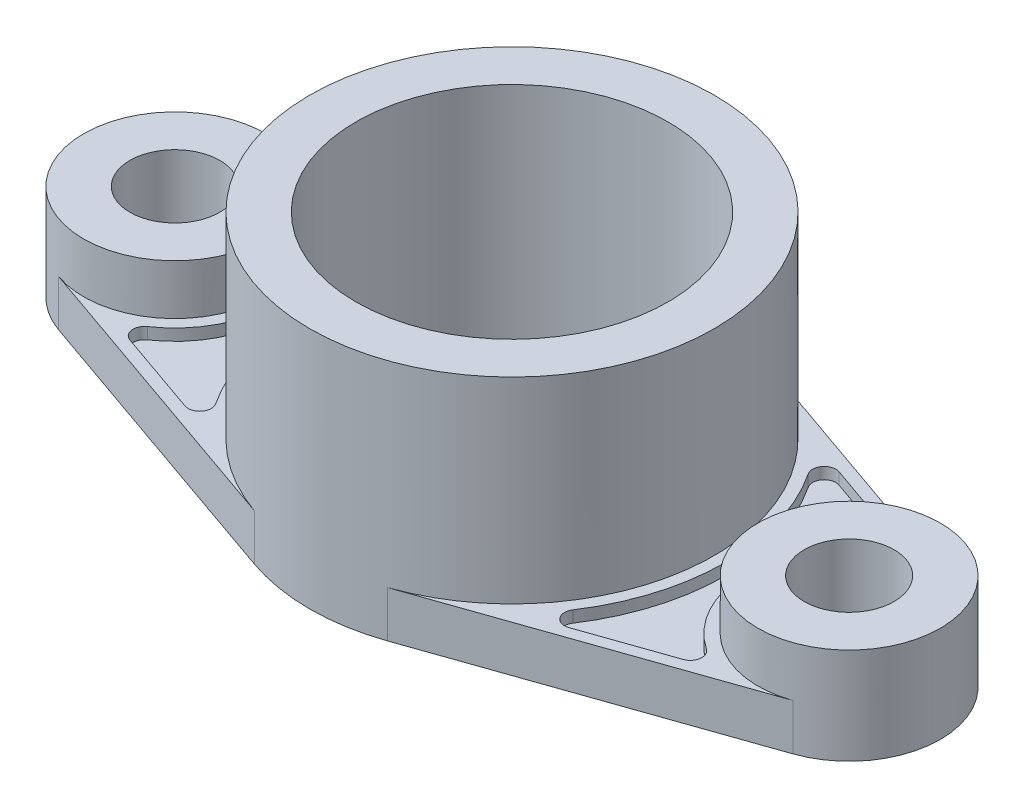
from build123d import *

# Parameters (mm, degrees)
BOSS_EXTRUDE1_DEPTH = 12
BOSS_EXTRUDE2_DEPTH = 9
BOSS_EXTRUDE3_DEPTH = 12
SKETCH1_5_R         = 40.5
BOSS_EXTRUDE4_DEPTH = 63
SKETCH1_6_R         = 23.665
SKETCH1_6_R_2       = 11.665
BOSS_EXTRUDE5_DEPTH = 25


with BuildPart() as part:
    # Sketch1 → Boss-Extrude1 (new body)
    with BuildSketch(Plane(origin=(0, 0, 0), x_dir=(1, 0, 0), z_dir=(0, 1, 0))):
        with BuildLine():
            Line((95.298631714, 22.343087709), (17.301, 49.56738241))
            ThreePointArc((17.301, 49.56738241), (42.805096075, 30.396936523), (52.5, 0))
            ThreePointArc((52.5, 0), (42.805096075, -30.396936523), (17.301, -49.56738241))
            Line((17.301, -49.56738241), (95.298631714, -22.343087709))
            ThreePointArc((95.298631714, -22.343087709), (63.835, 0), (95.298631714, 22.343087709))
        make_face()
        with BuildLine():
            Line((71.809327621, -27.364302024), (49.82603874, -35.037349549))
            ThreePointArc((49.82603874, -35.037349549), (46.470783868, -34.048587089), (46.332927596, -30.553392944))
            ThreePointArc((46.332927596, -30.553392944), (55.5, 0), (46.332927596, 30.553392944))
            ThreePointArc((46.332927596, 30.553392944), (46.470783868, 34.048587089), (49.82603874, 35.037349549))
            Line((49.82603874, 35.037349549), (71.809327621, 27.364302024))
            ThreePointArc((71.809327621, 27.364302024), (73.795133067, 24.922702734), (72.507464694, 22.050988869))
            ThreePointArc((72.507464694, 22.050988869), (60.835, 0), (72.507464694, -22.050988869))
            ThreePointArc((72.507464694, -22.050988869), (73.795133067, -24.922702734), (71.809327621, -27.364302024))
        make_face(mode=Mode.SUBTRACT)
    extrude(amount=BOSS_EXTRUDE1_DEPTH)

    # Sketch1_3 → Boss-Extrude2 (add)
    with BuildSketch(Plane(origin=(0, 0, 0), x_dir=(1, 0, 0), z_dir=(0, 1, 0))):
        with BuildLine():
            Line((-49.82603874, 35.037349549), (-71.809327621, 27.364302024))
            ThreePointArc((-71.809327621, 27.364302024), (-73.795133067, 24.922702734), (-72.507464694, 22.050988869))
            ThreePointArc((-72.507464694, 22.050988869), (-60.835, 0), (-72.507464694, -22.050988869))
            ThreePointArc((-72.507464694, -22.050988869), (-73.795133067, -24.922702734), (-71.809327621, -27.364302024))
            Line((-71.809327621, -27.364302024), (-49.82603874, -35.037349549))
            ThreePointArc((-49.82603874, -35.037349549), (-46.470783868, -34.048587089), (-46.332927596, -30.553392944))
            ThreePointArc((-46.332927596, -30.553392944), (-55.5, 0), (-46.332927596, 30.553392944))
            ThreePointArc((-46.332927596, 30.553392944), (-46.470783868, 34.048587089), (-49.82603874, 35.037349549))
        make_face()
        with BuildLine():
            ThreePointArc((46.332927596, -30.553392944), (46.470783868, -34.048587089), (49.82603874, -35.037349549))
            Line((49.82603874, -35.037349549), (71.809327621, -27.364302024))
            ThreePointArc((71.809327621, -27.364302024), (73.795133067, -24.922702734), (72.507464694, -22.050988869))
            ThreePointArc((72.507464694, -22.050988869), (60.835, 0), (72.507464694, 22.050988869))
            ThreePointArc((72.507464694, 22.050988869), (73.795133067, 24.922702734), (71.809327621, 27.364302024))
            Line((71.809327621, 27.364302024), (49.82603874, 35.037349549))
            ThreePointArc((49.82603874, 35.037349549), (46.470783868, 34.048587089), (46.332927596, 30.553392944))
            ThreePointArc((46.332927596, 30.553392944), (55.5, 0), (46.332927596, -30.553392944))
        make_face()
    extrude(amount=BOSS_EXTRUDE2_DEPTH)


with BuildPart() as boss_extrude2_piece_1:
    # of the separate pieces the step leaves, piece 1, a body of its own (boss_extrude2_pieces)
    add(part.part.solids().sort_by_distance((17.301, 0, 49.56738241))[0])



with BuildPart() as boss_extrude2_piece_2:
    # of the separate pieces the step leaves, piece 2, a body of its own (boss_extrude2_pieces)
    add(part.part.solids().sort_by_distance((-46.332927596, 0, -30.553392944))[0])

    # Sketch1_4 → Boss-Extrude3 (add)
    with BuildSketch(Plane(origin=(0, 0, 0), x_dir=(1, 0, 0), z_dir=(0, 1, 0))):
        with BuildLine():
            Line((-37.609789084, 42.478802323), (-95.298631714, 22.343087709))
            ThreePointArc((-95.298631714, 22.343087709), (-73.798218994, 19.29490664), (-63.835, 0))
            ThreePointArc((-63.835, 0), (-73.798218994, -19.29490664), (-95.298631714, -22.343087709))
            Line((-95.298631714, -22.343087709), (-17.301, -49.56738241))
            ThreePointArc((-17.301, -49.56738241), (-52.498391324, -0.410984604), (-18.074910259, 49.290441458))
            Line((-18.074910259, 49.290441458), (-37.609789084, 42.478802323))
        make_face()
        with BuildLine():
            ThreePointArc((-72.507464694, 22.050988869), (-73.795133067, 24.922702734), (-71.809327621, 27.364302024))
            Line((-71.809327621, 27.364302024), (-49.82603874, 35.037349549))
            ThreePointArc((-49.82603874, 35.037349549), (-46.470783868, 34.048587089), (-46.332927596, 30.553392944))
            ThreePointArc((-46.332927596, 30.553392944), (-55.5, 0), (-46.332927596, -30.553392944))
            ThreePointArc((-46.332927596, -30.553392944), (-46.470783868, -34.048587089), (-49.82603874, -35.037349549))
            Line((-49.82603874, -35.037349549), (-71.809327621, -27.364302024))
            ThreePointArc((-71.809327621, -27.364302024), (-73.795133067, -24.922702734), (-72.507464694, -22.050988869))
            ThreePointArc((-72.507464694, -22.050988869), (-60.835, 0), (-72.507464694, 22.050988869))
        make_face(mode=Mode.SUBTRACT)
    extrude(amount=BOSS_EXTRUDE3_DEPTH)


with BuildPart() as boss_extrude2_piece_1_1:
    add(boss_extrude2_piece_1.part)

    add(boss_extrude2_piece_2.part)  # Boss-Extrude4 merges Boss-Extrude2 piece 2
    # Sketch1_5 → Boss-Extrude4 (add)
    with BuildSketch(Plane(origin=(0, 0, 0), x_dir=(1, 0, 0), z_dir=(0, 1, 0))):
        with BuildLine():
            ThreePointArc((17.301, 49.56738241), (-0.410984604, 52.498391324), (-18.074910259, 49.290441458))
            ThreePointArc((-18.074910259, 49.290441458), (-52.498391324, -0.410984604), (-17.301, -49.56738241))
            ThreePointArc((-17.301, -49.56738241), (0, -52.5), (17.301, -49.56738241))
            ThreePointArc((17.301, -49.56738241), (42.805096075, -30.396936523), (52.5, 0))
            ThreePointArc((52.5, 0), (42.805096075, 30.396936523), (17.301, 49.56738241))
        make_face()
        Circle(SKETCH1_5_R, mode=Mode.SUBTRACT)
    extrude(amount=BOSS_EXTRUDE4_DEPTH)

    # Sketch1_6 → Boss-Extrude5 (add)
    # profile 1 of 2: a face of its own
    with BuildSketch(Plane(origin=(0, 0, 0), x_dir=(1, 0, 0), z_dir=(0, 1, 0))):
        with Locations((-87.5, 0)):
            Circle(SKETCH1_6_R)
        with Locations((-87.5, 0)):
            Circle(SKETCH1_6_R_2, mode=Mode.SUBTRACT)
    # profile 2 of 2: a face of its own
    with BuildSketch(Plane(origin=(0, 0, 0), x_dir=(1, 0, 0), z_dir=(0, 1, 0))):
        with Locations((87.5, 0)):
            Circle(SKETCH1_6_R)
        with Locations((87.5, 0)):
            Circle(SKETCH1_6_R_2, mode=Mode.SUBTRACT)
    extrude(amount=BOSS_EXTRUDE5_DEPTH)


solid = boss_extrude2_piece_1_1.part
